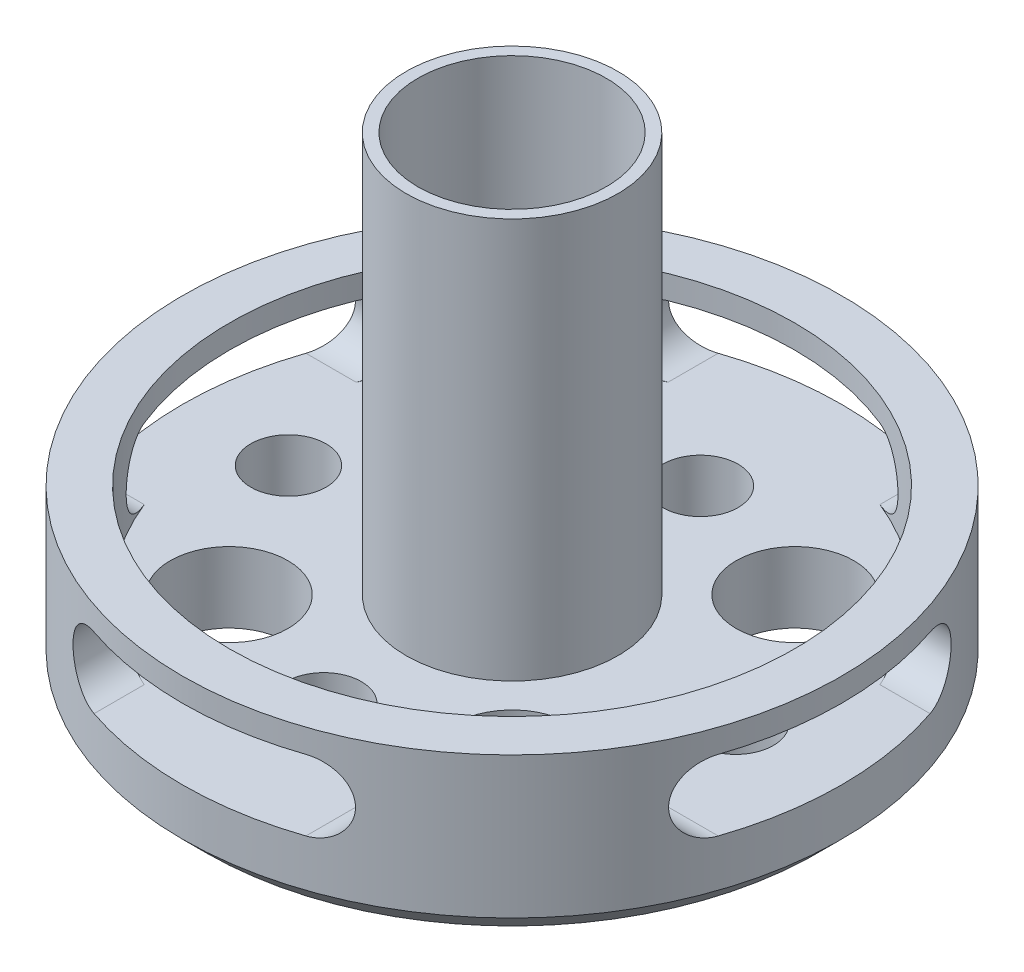
from build123d import *

# Parameters (mm, degrees)
SKETCH1_R            = 14
BOSS_EXTRUDE1_DEPTH  = 7
CHAMFER1_SIZE        = 1
SKETCH11_R           = 12
CUT_EXTRUDE3_DEPTH   = 4
M3_CLEARANCE_HOLE2_D = 3.2
SKETCH2_R            = 4
SKETCH2_R_2          = 2.5
CUT_EXTRUDE4_DEPTH   = 3
CHAMFER2_SIZE        = 0.5
CUT_EXTRUDE2_DEPTH   = 14
CIRPATTERN1_COUNT    = 4
SKETCH12_R           = 4.5
SKETCH12_R_2         = 4
BOSS_EXTRUDE3_DEPTH  = 17


with BuildPart() as part:
    # Sketch1 → Boss-Extrude1 (new body)
    with BuildSketch(Plane(origin=(0, 0, 0), x_dir=(1, 0, 0), z_dir=(0, 1, 0))):
        Circle(SKETCH1_R)
    extrude(amount=BOSS_EXTRUDE1_DEPTH)

    # Chamfer1
    chamfer1_edges = [part.edges().sort_by_distance(p)[0] for p in [
        (-14, 0, 0),
    ]]
    chamfer(chamfer1_edges, length=CHAMFER1_SIZE)

    # Sketch11 → Cut-Extrude3 (cut)
    with BuildSketch(Plane(origin=(0, 7, 0), x_dir=(1, 0, 0), z_dir=(0, 1, 0))):
        Circle(SKETCH11_R)
    extrude(amount=-CUT_EXTRUDE3_DEPTH, mode=Mode.SUBTRACT)

    # M3 Clearance Hole2 (through all)
    with Locations(Plane(origin=(0, 0, 0), x_dir=(-1, 0, 0), z_dir=(0, -1, 0))):
        with Locations((9.5, 0), (-9.5, 0), (0, 8), (0, -8)):
            Hole(M3_CLEARANCE_HOLE2_D / 2)

    # Sketch2 → Cut-Extrude4 (cut)
    with BuildSketch(Plane.XZ):
        Circle(SKETCH2_R)
        with Locations((6.01040764, 6.01040764)):
            Circle(SKETCH2_R_2)
        with Locations((6.01040764, -6.01040764)):
            Circle(SKETCH2_R_2)
        with Locations((-6.01040764, -6.01040764)):
            Circle(SKETCH2_R_2)
        with Locations((-6.01040764, 6.01040764)):
            Circle(SKETCH2_R_2)
    extrude(amount=-CUT_EXTRUDE4_DEPTH, mode=Mode.SUBTRACT)

    # Chamfer2
    chamfer2_edges = [part.edges().sort_by_distance(p)[0] for p in [
        (-4, 0, 0),
    ]]
    chamfer(chamfer2_edges, length=CHAMFER2_SIZE)

    # Sketch10 → Cut-Extrude2 (cut)
    with BuildSketch(Plane(origin=(0, 0, 0), x_dir=(0, 0, -1), z_dir=(1, 0, 0))):
        with BuildLine():
            Line((-4.5, 6), (4.5, 6))
            ThreePointArc((4.5, 6), (6, 4.5), (4.5, 3))
            Line((4.5, 3), (-4.5, 3))
            ThreePointArc((-4.5, 3), (-6, 4.5), (-4.5, 6))
        make_face()
    cut_extrude2 = extrude(amount=-CUT_EXTRUDE2_DEPTH, mode=Mode.SUBTRACT)

    # CirPattern1: Cut-Extrude2 ×4 about axis
    cirpattern1_axis = Axis((0, 3, 0), (0, 1, 0))
    for i in range(1, CIRPATTERN1_COUNT):
        add(cut_extrude2.rotate(cirpattern1_axis, i * 360 / CIRPATTERN1_COUNT), mode=Mode.SUBTRACT)

    # Sketch12 → Boss-Extrude3 (add)
    with BuildSketch(Plane(origin=(0, 3, 0), x_dir=(1, 0, 0), z_dir=(0, 1, 0))):
        Circle(SKETCH12_R)
        Circle(SKETCH12_R_2, mode=Mode.SUBTRACT)
    extrude(amount=BOSS_EXTRUDE3_DEPTH)


solid = part.part
